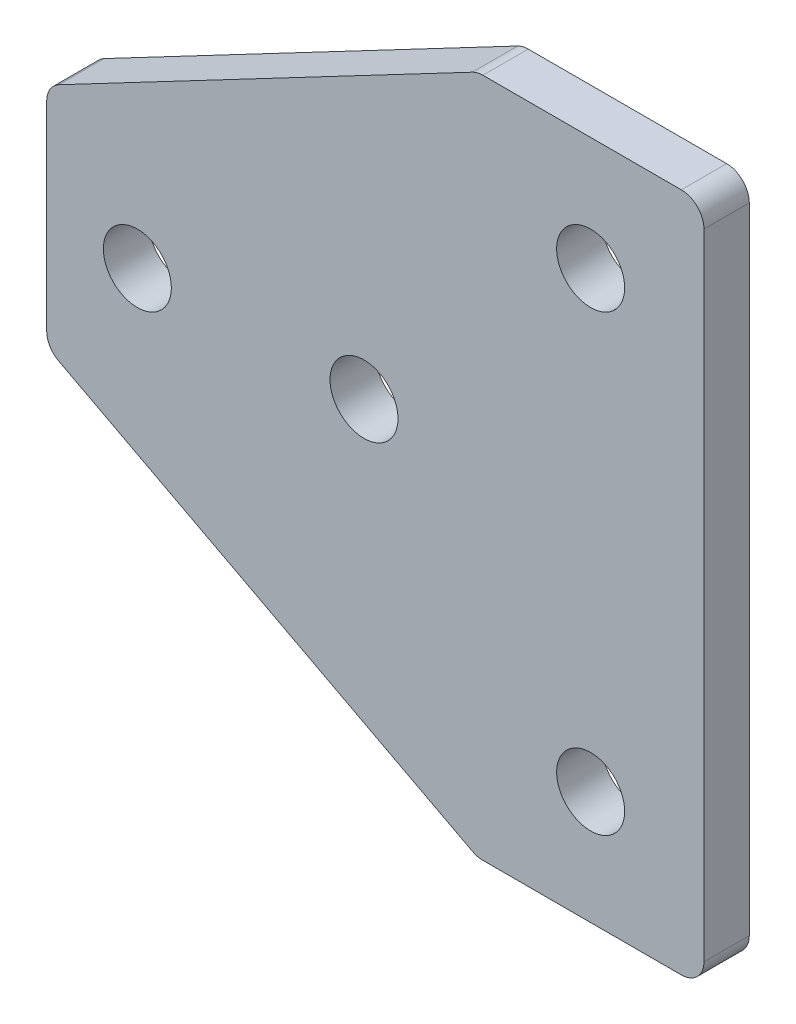
from build123d import *

# Parameters (mm, degrees)
SKETCH_1_R      = 1.5
EXTRUDE_1_DEPTH = 2
FILLET_1_R      = 1


with BuildPart() as part:
    # 草图1 → 凸台-拉伸1 (new body)
    with BuildSketch(Plane.XY):
        Polygon((0, 15), (0, -15), (-10, -15), (-29, -5), (-29, 5), (-10, 15), align=None)
        with Locations((-15, 0)):
            Circle(SKETCH_1_R, mode=Mode.SUBTRACT)
        with Locations((-5, -10)):
            Circle(SKETCH_1_R, mode=Mode.SUBTRACT)
        with Locations((-5, 10)):
            Circle(SKETCH_1_R, mode=Mode.SUBTRACT)
        with Locations((-25, 0)):
            Circle(SKETCH_1_R, mode=Mode.SUBTRACT)
    extrude(amount=EXTRUDE_1_DEPTH)

    # 圆角1
    fillet_1_edges = [part.edges().sort_by_distance(p)[0] for p in [
        (0, 15, 1),
        (0, -15, 1),
        (-10, -15, 1),
        (-29, -5, 1),
        (-29, 5, 1),
        (-10, 15, 1),
    ]]
    fillet(fillet_1_edges, radius=FILLET_1_R)


solid = part.part
